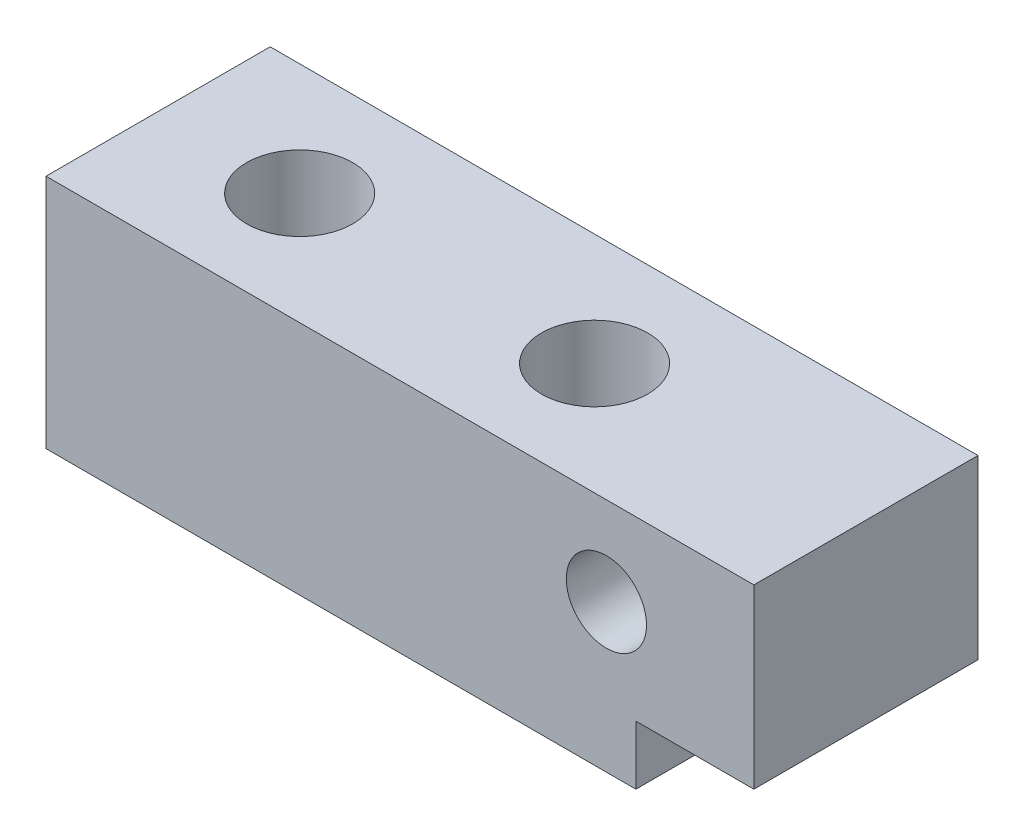
from build123d import *

# Parameters (mm, degrees)
SKETCH1_W                = 60
SKETCH1_H                = 20
BOSS_EXTRUDE1_DEPTH      = 9.5
SKETCH2_W                = 10
SKETCH2_H                = 5
CUT_EXTRUDE1_DEPTH       = 20
F_9_0_9_DIAMETER_HOLE1_D = 9
M8X1_25_TAPPED_HOLE1_D   = 6.8


with BuildPart() as part:
    # Sketch1 → Boss-Extrude1 (new body, symmetric)
    with BuildSketch(Plane.XY):
        with Locations((30, 10)):
            Rectangle(SKETCH1_W, SKETCH1_H)
    extrude(amount=BOSS_EXTRUDE1_DEPTH, both=True)

    # Sketch2 → Cut-Extrude1 (cut, through all)
    with BuildSketch(Plane.XY.offset(9.5)):
        with Locations((55, 2.5)):
            Rectangle(SKETCH2_W, SKETCH2_H)
    extrude(amount=-CUT_EXTRUDE1_DEPTH, mode=Mode.SUBTRACT)

    # Ø9.0 (9) Diameter Hole1 (through all)
    with Locations(Plane(origin=(0, 20, 0), x_dir=(-1, 0, 0), z_dir=(0, 1, 0))):
        with Locations((-12, 0), (-37, 0)):
            Hole(F_9_0_9_DIAMETER_HOLE1_D / 2)

    # M8x1.25 Tapped Hole1 (through all)
    with Locations(Plane.XY.offset(9.5)):
        with Locations((47.5, 12.5)):
            Hole(M8X1_25_TAPPED_HOLE1_D / 2)


solid = part.part
